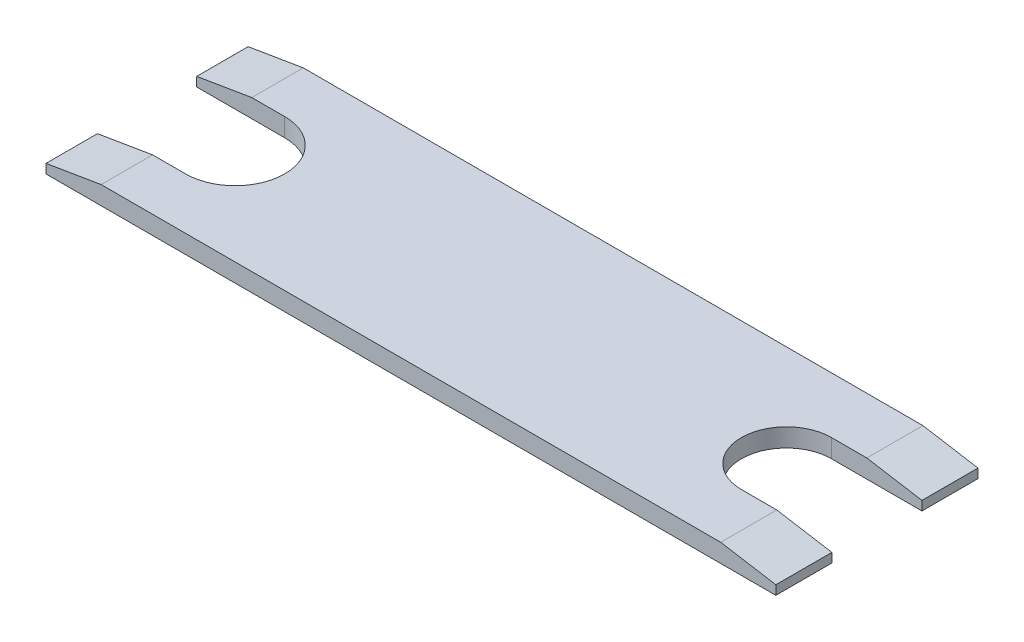
from build123d import *

# Parameters (mm, degrees)
SKETCH1_R           = 2.7
SKETCH1_R_2         = 2.45
BOSS_EXTRUDE1_DEPTH = 1
SKETCH2_W           = 5.5
SKETCH2_H           = 5.4
SKETCH2_H_2         = 4.9
CUT_EXTRUDE1_DEPTH  = 2
BOSS_EXTRUDE2_DEPTH = 1
CHAMFER1_SIZE       = 3
CHAMFER1_SIZE2      = 0.5


with BuildPart() as part:
    # Sketch1 → Boss-Extrude1 (new body)
    with BuildSketch(Plane(origin=(0, 0, 0), x_dir=(1, 0, 0), z_dir=(0, 1, 0))):
        with BuildLine():
            Line((-15, 5.5), (15, 5.5))
            ThreePointArc((15, 5.5), (20.5, 0), (15, -5.5))
            Line((15, -5.5), (-15, -5.5))
            ThreePointArc((-15, -5.5), (-20.5, 0), (-15, 5.5))
        make_face()
        with Locations((-15, 0)):
            Circle(SKETCH1_R, mode=Mode.SUBTRACT)
        with Locations((15, 0)):
            Circle(SKETCH1_R_2, mode=Mode.SUBTRACT)
    extrude(amount=BOSS_EXTRUDE1_DEPTH)

    # Sketch2 → Cut-Extrude1 (cut, through all)
    with BuildSketch(Plane(origin=(0, 1, 0), x_dir=(1, 0, 0), z_dir=(0, 1, 0))):
        with Locations((-17.75, 0)):
            Rectangle(SKETCH2_W, SKETCH2_H)
        with Locations((17.75, 0)):
            Rectangle(SKETCH2_W, SKETCH2_H_2)
    extrude(amount=-CUT_EXTRUDE1_DEPTH, mode=Mode.SUBTRACT)

    # Sketch3 → Boss-Extrude2 (add)
    with BuildSketch(Plane.XZ):
        with BuildLine():
            Line((-19.79165942, 2.7), (-19.79165942, 5.5))
            Line((-19.79165942, 5.5), (-15, 5.5))
            ThreePointArc((-15, 5.5), (-17.774887385, 4.748684028), (-19.79165942, 2.7))
        make_face()
        with BuildLine():
            Line((15, 5.5), (19.924175058, 5.5))
            Line((19.924175058, 5.5), (19.924175058, 2.45))
            ThreePointArc((19.924175058, 2.45), (17.896118092, 4.675735236), (15, 5.5))
        make_face()
        with BuildLine():
            Line((19.924175058, -2.45), (19.924175058, -5.5))
            Line((19.924175058, -5.5), (15, -5.5))
            ThreePointArc((15, -5.5), (17.896118092, -4.675735236), (19.924175058, -2.45))
        make_face()
        with BuildLine():
            Line((-15, -5.5), (-19.79165942, -5.5))
            Line((-19.79165942, -5.5), (-19.79165942, -2.7))
            ThreePointArc((-19.79165942, -2.7), (-17.774887385, -4.748684028), (-15, -5.5))
        make_face()
    extrude(amount=-BOSS_EXTRUDE2_DEPTH)

    # Chamfer1
    chamfer1_edges = [part.edges().sort_by_distance(p)[0] for p in [
        (19.924175058, 1, -3.975),
        (-19.79165942, 1, 4.1),
        (-19.79165942, 1, -4.1),
        (19.924175058, 1, 3.975),
    ]]
    chamfer1_side = [part.faces().sort_by_distance(p)[0] for p in [
        (0.231556515, 1, 0),
    ]]
    chamfer(chamfer1_edges, length=CHAMFER1_SIZE, length2=CHAMFER1_SIZE2, reference=chamfer1_side[0])


solid = part.part
